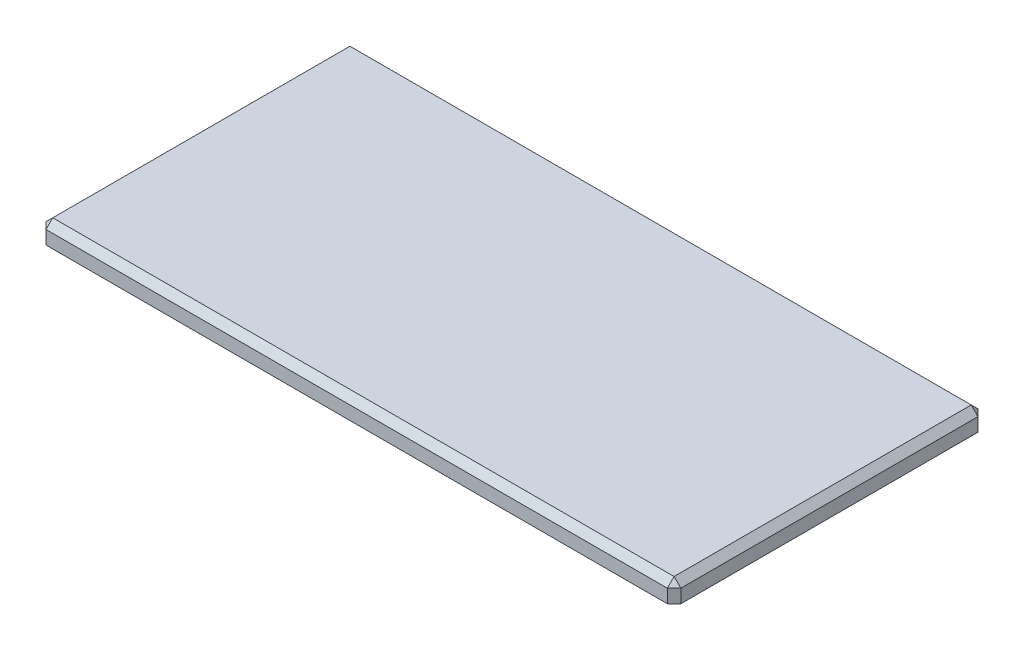
from build123d import *

# Parameters (mm, degrees)
SKETCH1_W           = 47
SKETCH1_H           = 23
BOSS_EXTRUDE1_DEPTH = 1.5
CHAMFER1_SIZE       = 0.5


with BuildPart() as part:
    # Sketch1 → Boss-Extrude1 (new body)
    with BuildSketch(Plane(origin=(0, 0, 0), x_dir=(1, 0, 0), z_dir=(0, 1, 0))):
        with Locations((-9.402777778, 2.331944444)):
            Rectangle(SKETCH1_W, SKETCH1_H)
    extrude(amount=BOSS_EXTRUDE1_DEPTH)

    # Chamfer1
    chamfer1_edges = [part.edges().sort_by_distance(p)[0] for p in [
        (14.097222222, 1.5, -2.331944444),
        (-9.402777778, 1.5, -13.831944444),
        (-32.902777778, 1.5, -2.331944444),
        (-32.902777778, 0.75, -13.831944444),
        (14.097222222, 0.75, -13.831944444),
        (14.097222222, 0.75, 9.168055556),
        (-32.902777778, 0.75, 9.168055556),
        (-9.402777778, 1.5, 9.168055556),
    ]]
    chamfer(chamfer1_edges, length=CHAMFER1_SIZE)


solid = part.part
